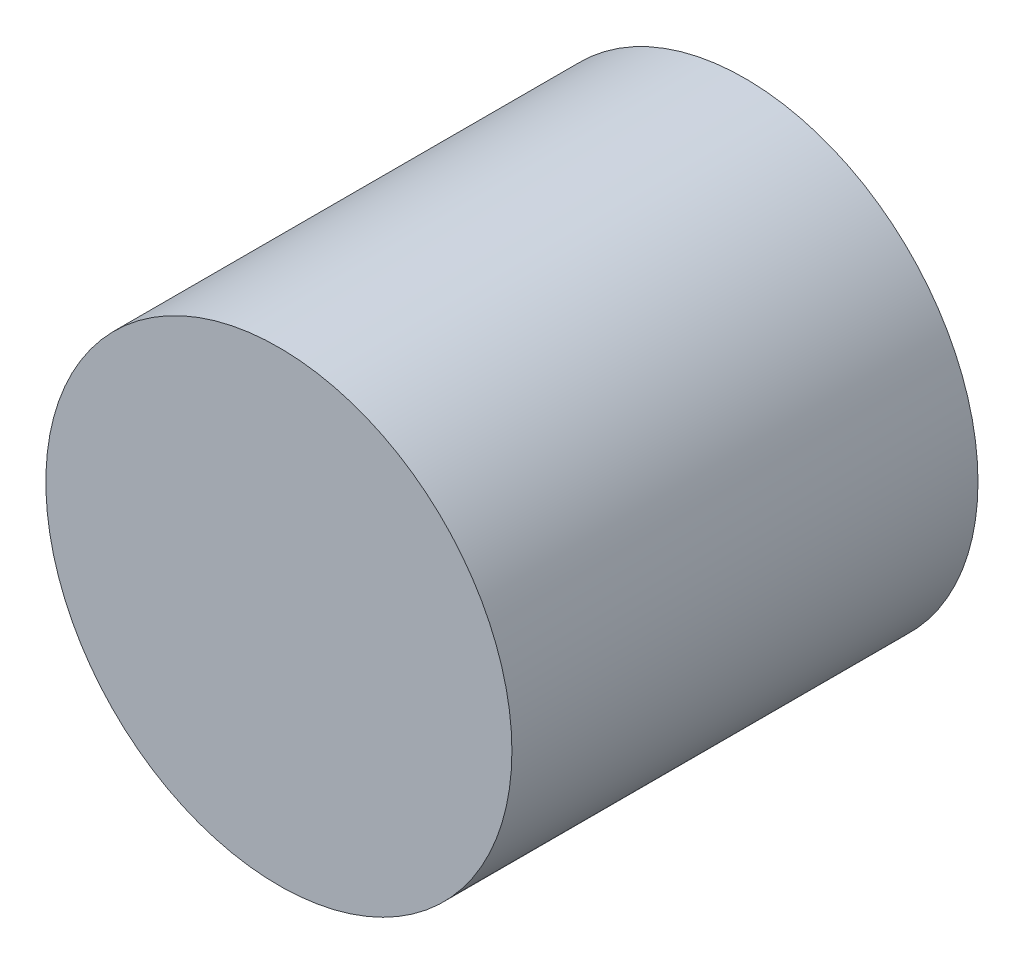
from build123d import *

# Parameters (mm, degrees)
SCHIZZO1_R                   = 0.5
ESTRUSIONE_ESTRUSIONE1_DEPTH = 0.5


with BuildPart() as part:
    # Schizzo1 → Estrusione-Estrusione1 (new body, symmetric)
    with BuildSketch(Plane.XY):
        Circle(SCHIZZO1_R)
    extrude(amount=ESTRUSIONE_ESTRUSIONE1_DEPTH, both=True)


solid = part.part
